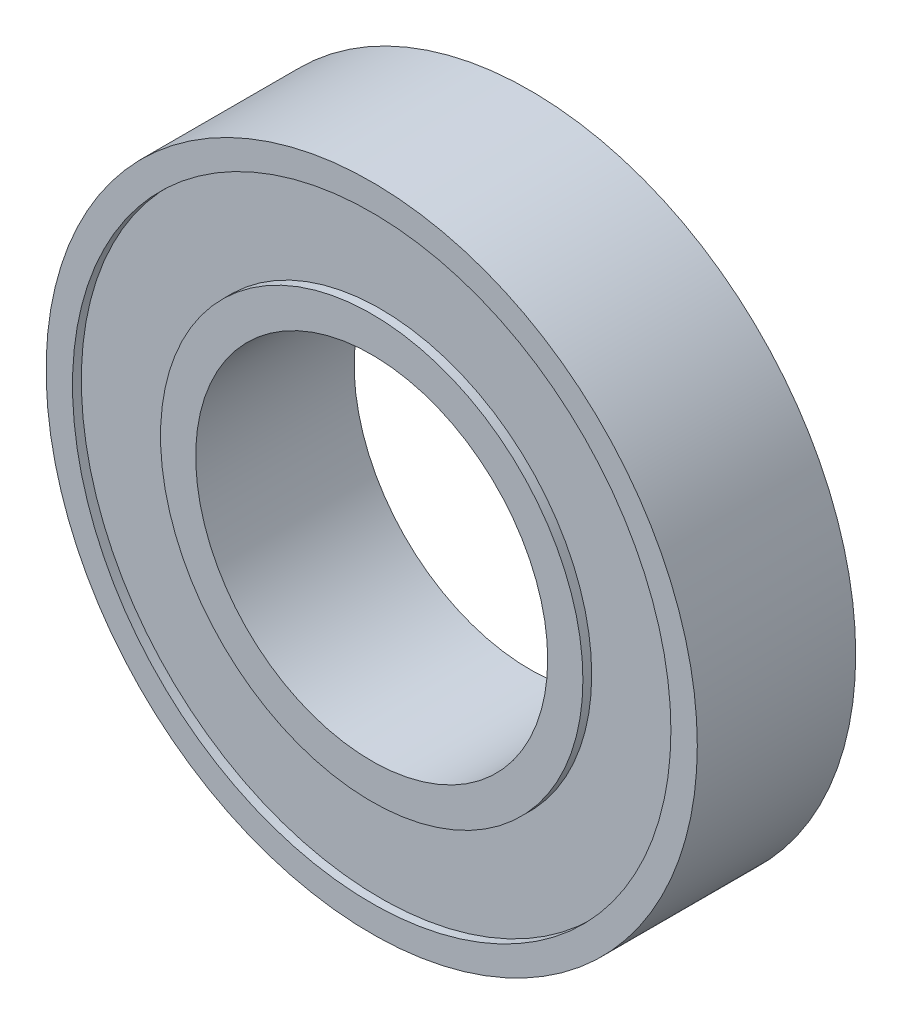
from build123d import *

# Parameters (mm, degrees)
SKETCH_1_R          = 18.5
EXTRUDE_1_DEPTH     = 4.5
SKETCH_2_R          = 10
CUT_EXTRUDE_1_DEPTH = 10
SKETCH_3_R          = 17
SKETCH_3_R_2        = 12
CUT_EXTRUDE_2_DEPTH = 0.5


with BuildPart() as part:
    # 草圖1 → 填料-伸長1 (new body, symmetric)
    with BuildSketch(Plane.XY):
        Circle(SKETCH_1_R)
    extrude(amount=EXTRUDE_1_DEPTH, both=True)

    # 草圖2 → 除料-伸長1 (cut, through all)
    with BuildSketch(Plane.XY.offset(4.5)):
        Circle(SKETCH_2_R)
    extrude(amount=-CUT_EXTRUDE_1_DEPTH, mode=Mode.SUBTRACT)

    # 草圖3 → 除料-伸長2 (cut)
    with BuildSketch(Plane.XY.offset(4.5)):
        Circle(SKETCH_3_R)
        Circle(SKETCH_3_R_2, mode=Mode.SUBTRACT)
    cut_extrude_2 = extrude(amount=-CUT_EXTRUDE_2_DEPTH, mode=Mode.SUBTRACT)

    # 鏡射1: 除料-伸長2 across plane
    add(cut_extrude_2.mirror(Plane.XY), mode=Mode.SUBTRACT)


solid = part.part
